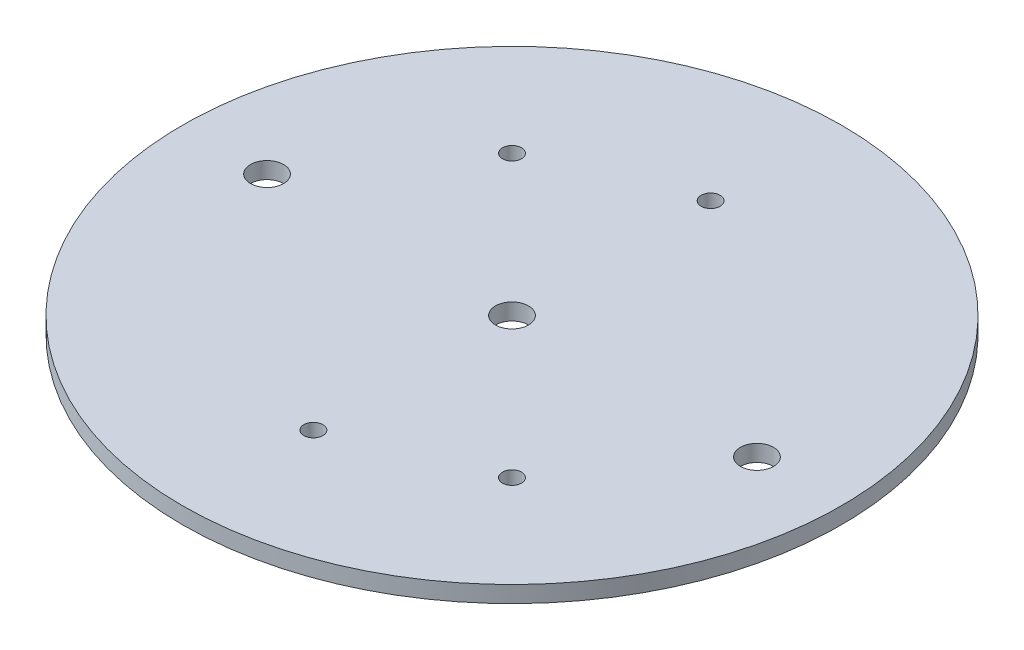
from build123d import *

# Parameters (mm, degrees)
SKETCH2_R           = 63.2206
SKETCH2_R_2         = 3.175
SKETCH2_R_3         = 1.8288
BOSS_EXTRUDE1_DEPTH = 3.175


with BuildPart() as part:
    # Sketch2 → Boss-Extrude1 (new body)
    with BuildSketch(Plane(origin=(0, 0, 0), x_dir=(1, 0, 0), z_dir=(0, 1, 0))):
        Circle(SKETCH2_R)
        with Locations((-46.99, 0)):
            Circle(SKETCH2_R_2, mode=Mode.SUBTRACT)
        with Locations((46.99, 0)):
            Circle(SKETCH2_R_2, mode=Mode.SUBTRACT)
        Circle(SKETCH2_R_2, mode=Mode.SUBTRACT)
        with Locations((0, 38.1)):
            Circle(SKETCH2_R_3, mode=Mode.SUBTRACT)
        with Locations((0, -38.1)):
            Circle(SKETCH2_R_3, mode=Mode.SUBTRACT)
        with Locations((-26.940768363, 26.940768363)):
            Circle(SKETCH2_R_3, mode=Mode.SUBTRACT)
        with Locations((26.940768363, -26.940768363)):
            Circle(SKETCH2_R_3, mode=Mode.SUBTRACT)
    extrude(amount=BOSS_EXTRUDE1_DEPTH)


solid = part.part
